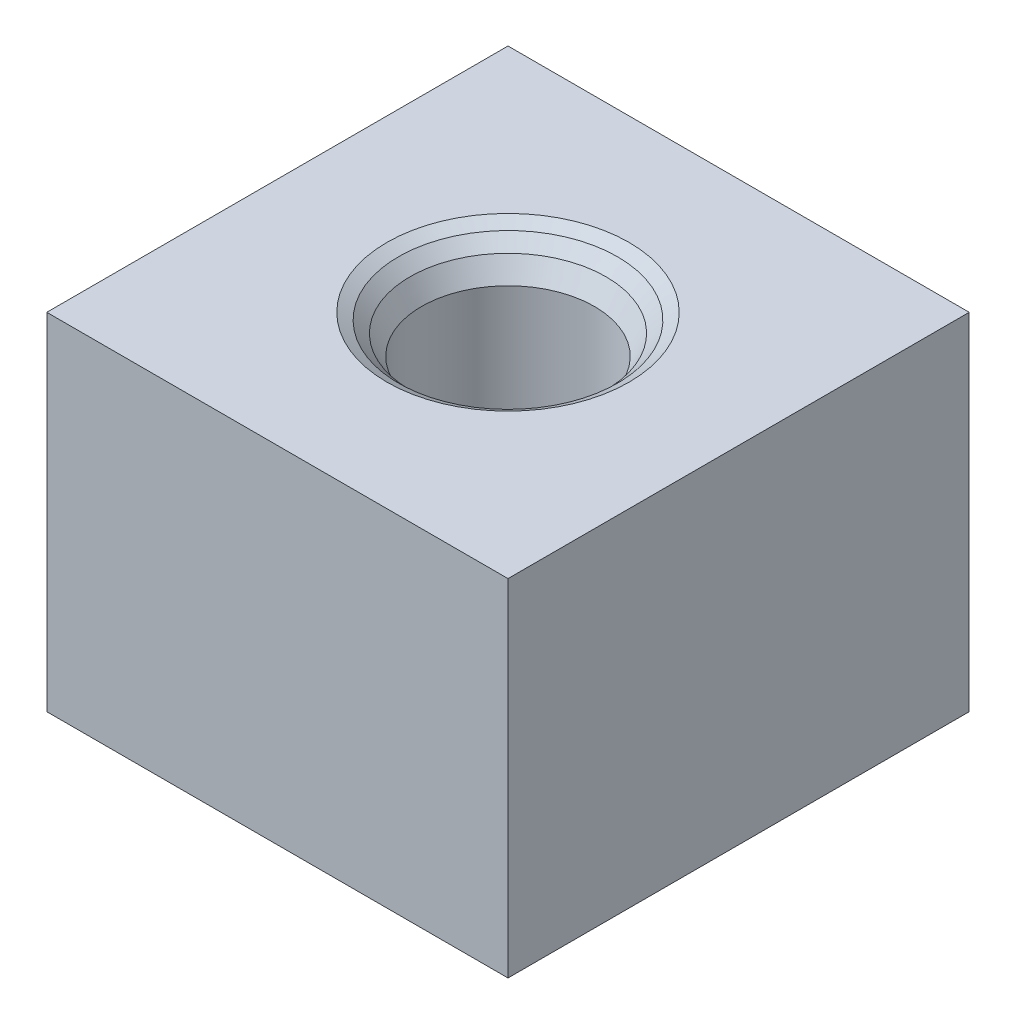
from build123d import *

# Parameters (mm, degrees)
SKETCH1_W           = 80
SKETCH1_H           = 80
BOSS_EXTRUDE1_DEPTH = 60


with BuildPart() as part:
    # Sketch1 → Boss-Extrude1 (new body)
    with BuildSketch(Plane(origin=(0, 0, 0), x_dir=(1, 0, 0), z_dir=(0, 1, 0))):
        Rectangle(SKETCH1_W, SKETCH1_H)
    extrude(amount=BOSS_EXTRUDE1_DEPTH)

    # Sketch2 → Cut-Revolve1 (revolve, cut)
    with BuildSketch(Plane.XY):
        Polygon((0, 60), (-21, 60), (-19, 58.845299462), (-17, 56.845299462), (-15, 53.381197846), (-15, 10), (0, 10), align=None)
    revolve(axis=Axis((0, 10, 0), (0, 1, 0)), mode=Mode.SUBTRACT)


solid = part.part
